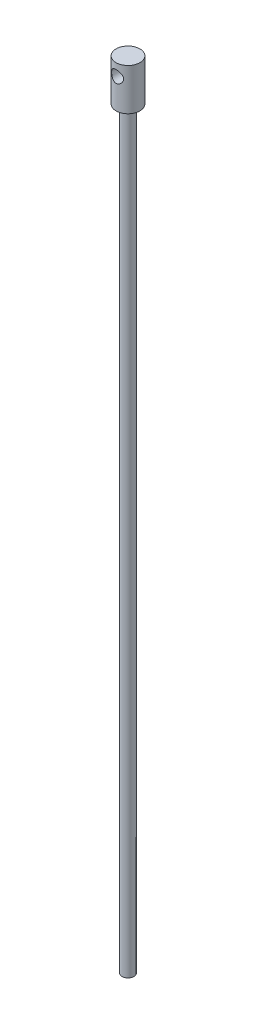
from build123d import *

# Parameters (mm, degrees)
CROQUIS1_R                   = 3
SALIENTE_EXTRUIR1_DEPTH      = 390
CROQUIS2_R                   = 6
CROQUIS2_R_2                 = 3
SALIENTE_EXTRUIR5_DEPTH      = 9
SALIENTE_EXTRUIR5_DEPTH_BACK = 12
CROQUIS8_R                   = 3
SALIENTE_EXTRUIR6_DEPTH      = 9
CROQUIS9_R                   = 3
CORTAR_EXTRUIR1_DEPTH        = 10


with BuildPart() as part:
    # Croquis1 → Saliente-Extruir1 (new body)
    with BuildSketch(Plane(origin=(0, 0, 0), x_dir=(1, 0, 0), z_dir=(0, 1, 0))):
        Circle(CROQUIS1_R)
    extrude(amount=SALIENTE_EXTRUIR1_DEPTH)

    # Croquis2 → Saliente-Extruir5 (add, two sides)
    with BuildSketch(Plane(origin=(0, 390, 0), x_dir=(1, 0, 0), z_dir=(0, 1, 0))) as saliente_extruir5_sk:
        Circle(CROQUIS2_R)
        Circle(CROQUIS2_R_2, mode=Mode.SUBTRACT)
    extrude(amount=SALIENTE_EXTRUIR5_DEPTH)
    extrude(saliente_extruir5_sk.sketch, amount=-SALIENTE_EXTRUIR5_DEPTH_BACK)

    # Croquis8 → Saliente-Extruir6 (add)
    with BuildSketch(Plane(origin=(0, 390, 0), x_dir=(1, 0, 0), z_dir=(0, 1, 0))):
        Circle(CROQUIS8_R)
    extrude(amount=SALIENTE_EXTRUIR6_DEPTH)

    # Croquis9 → Cortar-Extruir1 (cut, symmetric)
    with BuildSketch(Plane.XY):
        with Locations((0, 393)):
            Circle(CROQUIS9_R)
    extrude(amount=CORTAR_EXTRUIR1_DEPTH, both=True, mode=Mode.SUBTRACT)


solid = part.part
